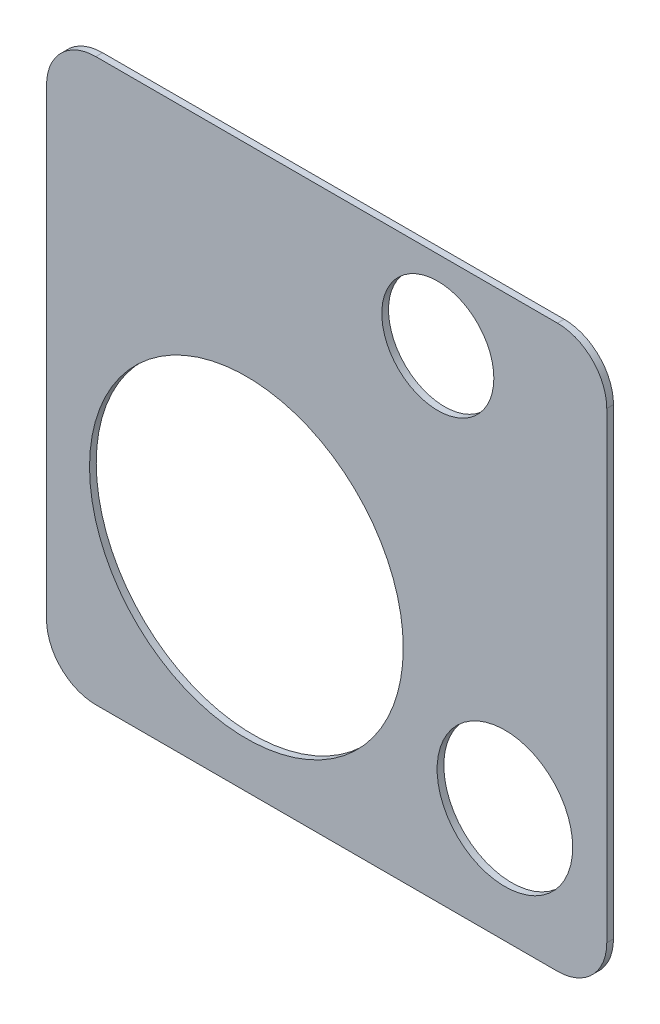
from build123d import *

# Parameters (mm, degrees)
SKETCH1_W           = 500
SKETCH1_H           = 501
BOSS_EXTRUDE1_DEPTH = 6
FILLET1_R           = 44
SKETCH3_R           = 140
CUT_EXTRUDE2_DEPTH  = 7
SKETCH5_R           = 60.5
CUT_EXTRUDE3_DEPTH  = 7
SKETCH6_R           = 50
CUT_EXTRUDE5_DEPTH  = 7


with BuildPart() as part:
    # Sketch1 → Boss-Extrude1 (new body)
    with BuildSketch(Plane.XY):
        with Locations((250, 250.5)):
            Rectangle(SKETCH1_W, SKETCH1_H)
    extrude(amount=BOSS_EXTRUDE1_DEPTH)

    # Fillet1
    fillet1_edges = [part.edges().sort_by_distance(p)[0] for p in [
        (0, 501, 3),
        (500, 501, 3),
        (500, 0, 3),
        (0, 0, 3),
    ]]
    fillet(fillet1_edges, radius=FILLET1_R)

    # Sketch3 → Cut-Extrude2 (cut, through all)
    with BuildSketch(Plane.XY.offset(6)):
        with Locations((178.369044072, 181.034738009)):
            Circle(SKETCH3_R)
    extrude(amount=-CUT_EXTRUDE2_DEPTH, mode=Mode.SUBTRACT)

    # Sketch5 → Cut-Extrude3 (cut, through all)
    with BuildSketch(Plane.XY.offset(6)):
        with Locations((409.103373264, 102.516190165)):
            Circle(SKETCH5_R)
    extrude(amount=-CUT_EXTRUDE3_DEPTH, mode=Mode.SUBTRACT)

    # Sketch6 → Cut-Extrude5 (cut, through all)
    with BuildSketch(Plane.XY.offset(6)):
        with Locations((349.228645131, 430)):
            Circle(SKETCH6_R)
    extrude(amount=-CUT_EXTRUDE5_DEPTH, mode=Mode.SUBTRACT)


solid = part.part
